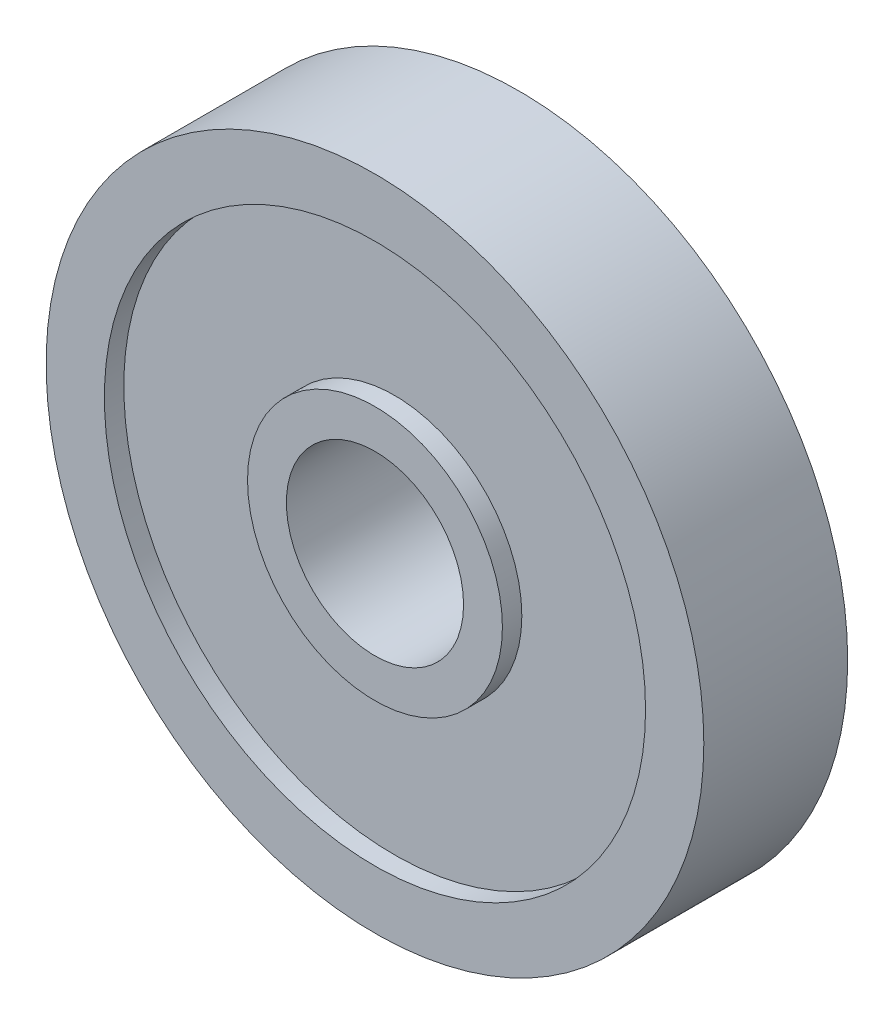
from build123d import *

# Parameters (mm, degrees)
SKETCH1_R           = 16.933333333
SKETCH1_R_2         = 4.5625
BOSS_EXTRUDE1_DEPTH = 7.408333333
SKETCH2_R           = 13.933333333
SKETCH2_R_2         = 6.5625
CUT_EXTRUDE1_DEPTH  = 1


with BuildPart() as part:
    # Sketch1 → Boss-Extrude1 (new body)
    with BuildSketch(Plane.XY):
        with Locations((-108.042890629, 14.636479869)):
            Circle(SKETCH1_R)
        with Locations((-108.042890629, 14.636479869)):
            Circle(SKETCH1_R_2, mode=Mode.SUBTRACT)
    extrude(amount=BOSS_EXTRUDE1_DEPTH)

    # Sketch2 → Cut-Extrude1 (cut)
    with BuildSketch(Plane.XY.offset(7.408333333)):
        with Locations((-108.042890629, 14.636479869)):
            Circle(SKETCH2_R)
        with Locations((-108.042890629, 14.636479869)):
            Circle(SKETCH2_R_2, mode=Mode.SUBTRACT)
    cut_extrude1 = extrude(amount=-CUT_EXTRUDE1_DEPTH, mode=Mode.SUBTRACT)

    # Mirror1: Cut-Extrude1 across plane
    add(cut_extrude1.mirror(Plane.XY.offset(3.704166667)), mode=Mode.SUBTRACT)


solid = part.part
